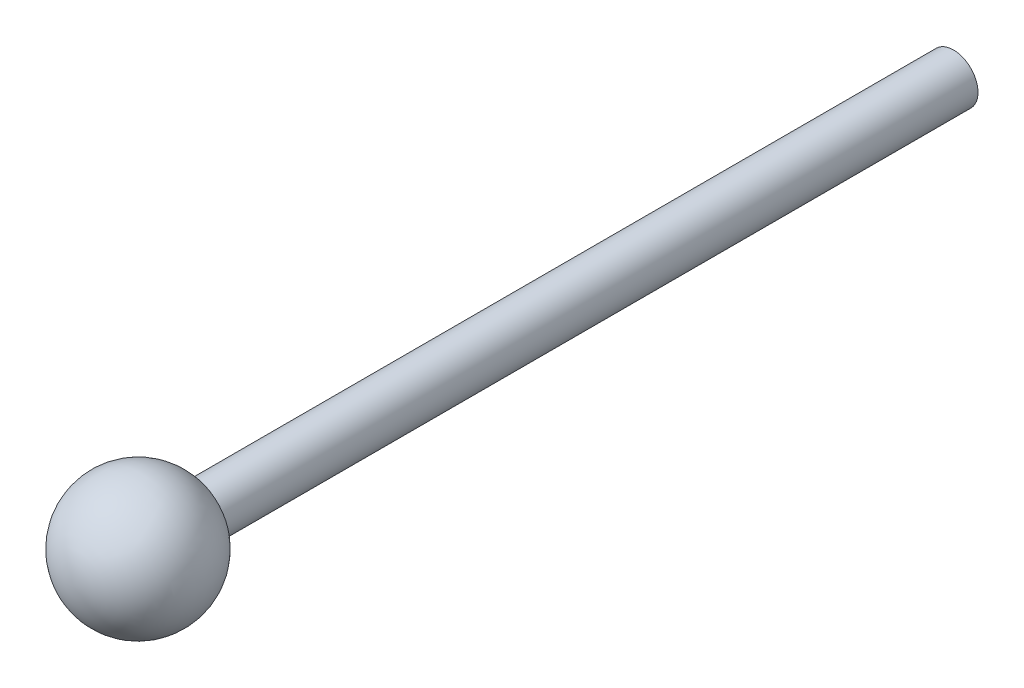
from build123d import *

# Parameters (mm, degrees)
SKETCH1_R          = 7.62
BASE_EXTRUDE_DEPTH = 254


with BuildPart() as part:
    # Sketch1 → Base-Extrude (new body)
    with BuildSketch(Plane.XY):
        Circle(SKETCH1_R)
    extrude(amount=-BASE_EXTRUDE_DEPTH)

    # Sketch5 → Boss-Revolve1 (revolve)
    with BuildSketch(Plane.XY):
        with BuildLine():
            Line((0, 20.32), (0, -20.32))
            ThreePointArc((0, -20.32), (20.32, 0), (0, 20.32))
        make_face()
    revolve(axis=Axis((0, 20.32, 0), (0, -1, 0)))


solid = part.part
